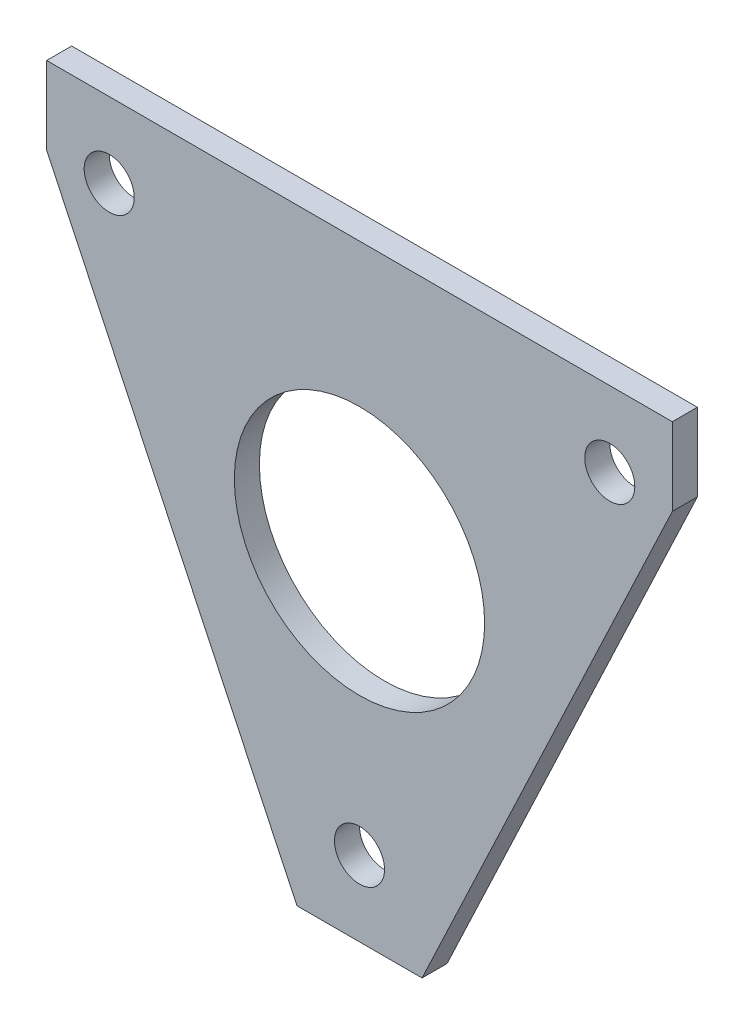
from build123d import *

# Parameters (mm, degrees)
SKETCH1_R           = 4
BOSS_EXTRUDE1_DEPTH = 4
SKETCH2_R           = 20
CUT_EXTRUDE1_DEPTH  = 10


with BuildPart() as part:
    # Sketch1 → Boss-Extrude1 (new body)
    with BuildSketch(Plane.XY):
        Polygon((-71.425004503, 17.68546584), (28.574995497, 17.68546584), (28.574995497, 5.27207622), (-11.425004503, -79.31453416), (-31.425004503, -79.31453416), (-71.425004503, 5.27207622), align=None)
        with Locations((-61.425004503, 5.68546584)):
            Circle(SKETCH1_R, mode=Mode.SUBTRACT)
        with Locations((18.574995497, 5.68546584)):
            Circle(SKETCH1_R, mode=Mode.SUBTRACT)
        with Locations((-21.425004503, -67.31453416)):
            Circle(SKETCH1_R, mode=Mode.SUBTRACT)
    extrude(amount=BOSS_EXTRUDE1_DEPTH)

    # Sketch2 → Cut-Extrude1 (cut)
    with BuildSketch(Plane.XY.offset(4)):
        with Locations((-21.425004503, -25.21253416)):
            Circle(SKETCH2_R)
    extrude(amount=-CUT_EXTRUDE1_DEPTH, mode=Mode.SUBTRACT)


solid = part.part
